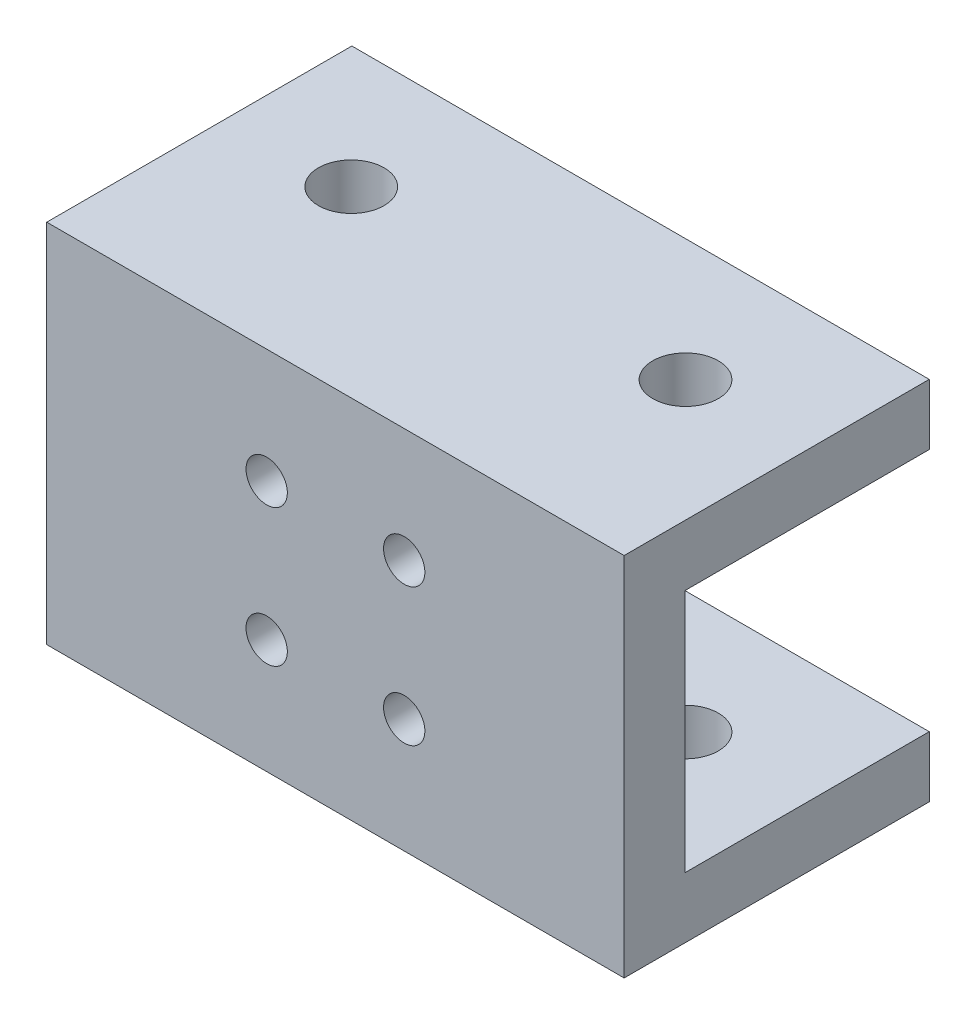
from build123d import *

# Parameters (mm, degrees)
BOSS_EXTRUDE1_DEPTH                             = 47.5
CSK_FOR_M3_FLAT_HEAD_MACHINE_SCREW1_D           = 3.4
CSK_FOR_M3_FLAT_HEAD_MACHINE_SCREW1_CSINK_D     = 6.3
CSK_FOR_M3_FLAT_HEAD_MACHINE_SCREW1_CSINK_ANGLE = 90
SKETCH5_R                                       = 2.7
CUT_EXTRUDE1_DEPTH                              = 31.1


with BuildPart() as part:
    # Sketch1 → Boss-Extrude1 (new body)
    with BuildSketch(Plane(origin=(0, 0, 0), x_dir=(0, 0, -1), z_dir=(1, 0, 0))):
        Polygon((10.05, -10.05), (10.05, -15.05), (-15.05, -15.05), (-15.05, 15.05), (10.05, 15.05), (10.05, 10.05), (-10.05, 10.05), (-10.05, -10.05), align=None)
    extrude(amount=BOSS_EXTRUDE1_DEPTH)

    # CSK for M3 Flat Head Machine Screw1 (through all)
    with Locations(Plane(origin=(0, 0, 10.05), x_dir=(-1, 0, 0), z_dir=(0, 0, -1))):
        with Locations((-29.406854249, 5.656854249), (-18.093145751, 5.656854249), (-18.093145751, -5.656854249), (-29.406854249, -5.656854249)):
            CounterSinkHole(CSK_FOR_M3_FLAT_HEAD_MACHINE_SCREW1_D / 2, CSK_FOR_M3_FLAT_HEAD_MACHINE_SCREW1_CSINK_D / 2, counter_sink_angle=CSK_FOR_M3_FLAT_HEAD_MACHINE_SCREW1_CSINK_ANGLE)

    # Sketch5 → Cut-Extrude1 (cut, through all)
    with BuildSketch(Plane(origin=(0, 15.05, 0), x_dir=(1, 0, 0), z_dir=(0, 1, 0))):
        with Locations((10, 0)):
            Circle(SKETCH5_R)
        with Locations((37.5, 0)):
            Circle(SKETCH5_R)
    extrude(amount=-CUT_EXTRUDE1_DEPTH, mode=Mode.SUBTRACT)


solid = part.part
